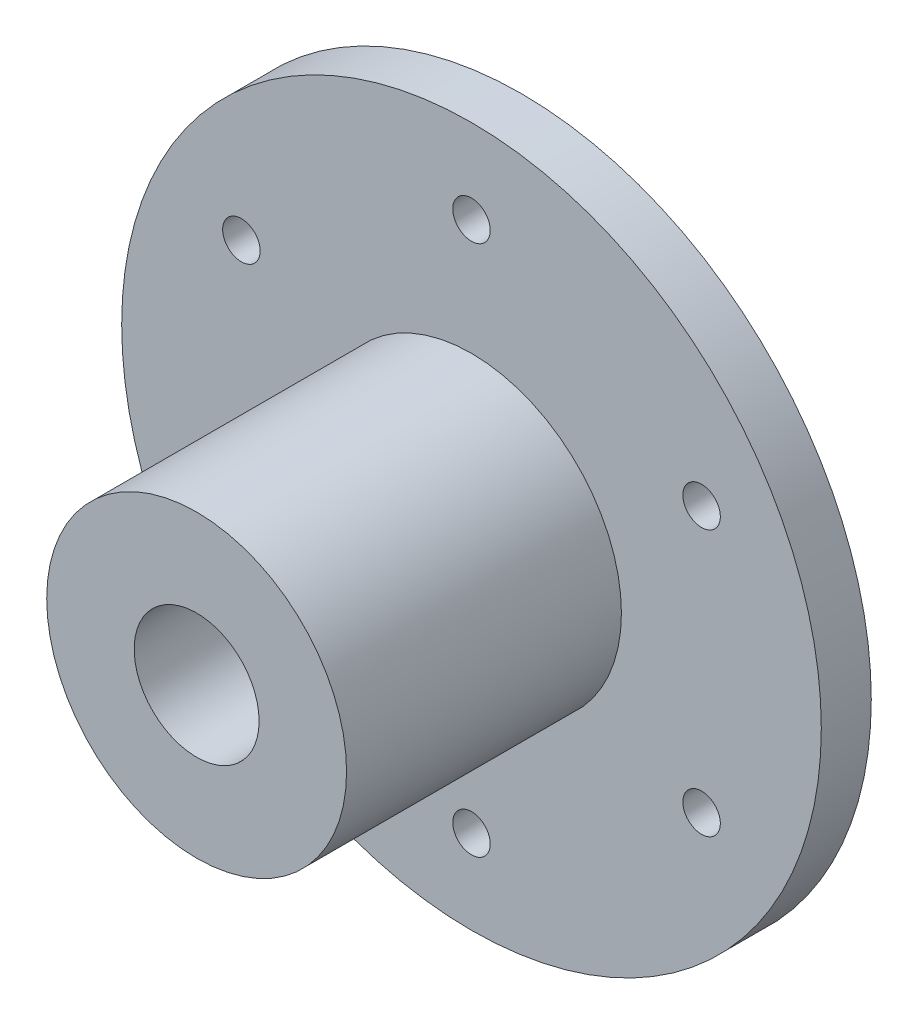
from build123d import *

# Parameters (mm, degrees)
SKETCH_1_R               = 28
EXTRUDE_1_DEPTH          = 4
SKETCH_2_R               = 12
EXTRUDE_2_DEPTH          = 22
SKETCH_3_R               = 5
CUT_EXTRUDE_1_DEPTH      = 60
SKETCH_4_R               = 1.5
CUT_EXTRUDE_2_DEPTH      = 7
PATTERN_CIRCULAR_1_COUNT = 6
SKETCH_5_R               = 1.5
CUT_EXTRUDE_3_DEPTH      = 15


with BuildPart() as part:
    # 草图1 → 凸台-拉伸1 (new body)
    with BuildSketch(Plane.XY):
        Circle(SKETCH_1_R)
    extrude(amount=EXTRUDE_1_DEPTH)

    # 草图2 → 凸台-拉伸2 (add)
    with BuildSketch(Plane.XY.offset(4)):
        Circle(SKETCH_2_R)
    extrude(amount=EXTRUDE_2_DEPTH)

    # 草图3 → 切除-拉伸1 (cut)
    with BuildSketch(Plane.XY.offset(26)):
        Circle(SKETCH_3_R)
    extrude(amount=-CUT_EXTRUDE_1_DEPTH, mode=Mode.SUBTRACT)

    # 草图4 → 切除-拉伸2 (cut)
    with BuildSketch(Plane(origin=(0, 0, 0), x_dir=(-1, 0, 0), z_dir=(0, 0, -1))):
        with Locations((0, 21.265645264)):
            Circle(SKETCH_4_R)
    cut_extrude_2 = extrude(amount=-CUT_EXTRUDE_2_DEPTH, mode=Mode.SUBTRACT)

    # 阵列(圆周)1: 切除-拉伸2 ×6 about axis
    pattern_circular_1_axis = Axis((0, 0, -1.3), (0, 0, 1))
    for i in range(1, PATTERN_CIRCULAR_1_COUNT):
        add(cut_extrude_2.rotate(pattern_circular_1_axis, i * 360 / PATTERN_CIRCULAR_1_COUNT), mode=Mode.SUBTRACT)

    # 草图5 → 切除-拉伸3 (cut)
    with BuildSketch(Plane(origin=(0, 0, 0), x_dir=(1, 0, 0), z_dir=(0, 1, 0))):
        with Locations((0, -16.223306721)):
            Circle(SKETCH_5_R)
    extrude(amount=-CUT_EXTRUDE_3_DEPTH, mode=Mode.SUBTRACT)


solid = part.part
